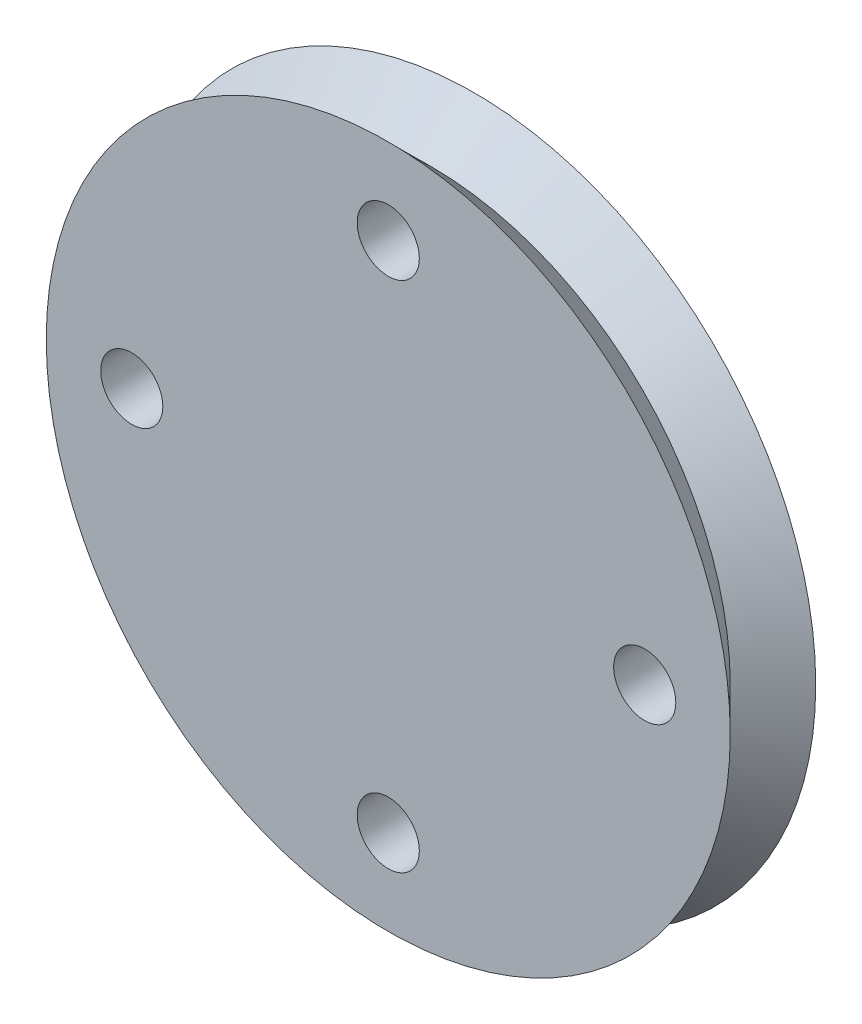
from build123d import *

# Parameters (mm, degrees)
SKETCH1_R           = 8
BOSS_EXTRUDE1_DEPTH = 2
SKETCH2_R           = 0.726422571
CUT_EXTRUDE1_DEPTH  = 2


with BuildPart() as part:
    # Sketch1 → Boss-Extrude1 (new body)
    with BuildSketch(Plane.XY):
        Circle(SKETCH1_R)
    extrude(amount=BOSS_EXTRUDE1_DEPTH)

    # Sketch2 → Cut-Extrude1 (cut)
    with BuildSketch(Plane.XY):
        with Locations((-6, 0)):
            Circle(SKETCH2_R)
        with Locations((0, 6)):
            Circle(SKETCH2_R)
        with Locations((6, 0)):
            Circle(SKETCH2_R)
        with Locations((0, -6)):
            Circle(SKETCH2_R)
    extrude(amount=CUT_EXTRUDE1_DEPTH, mode=Mode.SUBTRACT)

    # Sketch3 → Cut-Revolve1 (revolve, cut)
    with BuildSketch(Plane(origin=(0, 0, 0), x_dir=(0, 0, -1), z_dir=(1, 0, 0))):
        Polygon((-2, 8), (-1, 7), (0, 8), align=None)
    revolve(axis=Axis((0, 0, 3.502327543), (0, 0, -1)), mode=Mode.SUBTRACT)


solid = part.part
